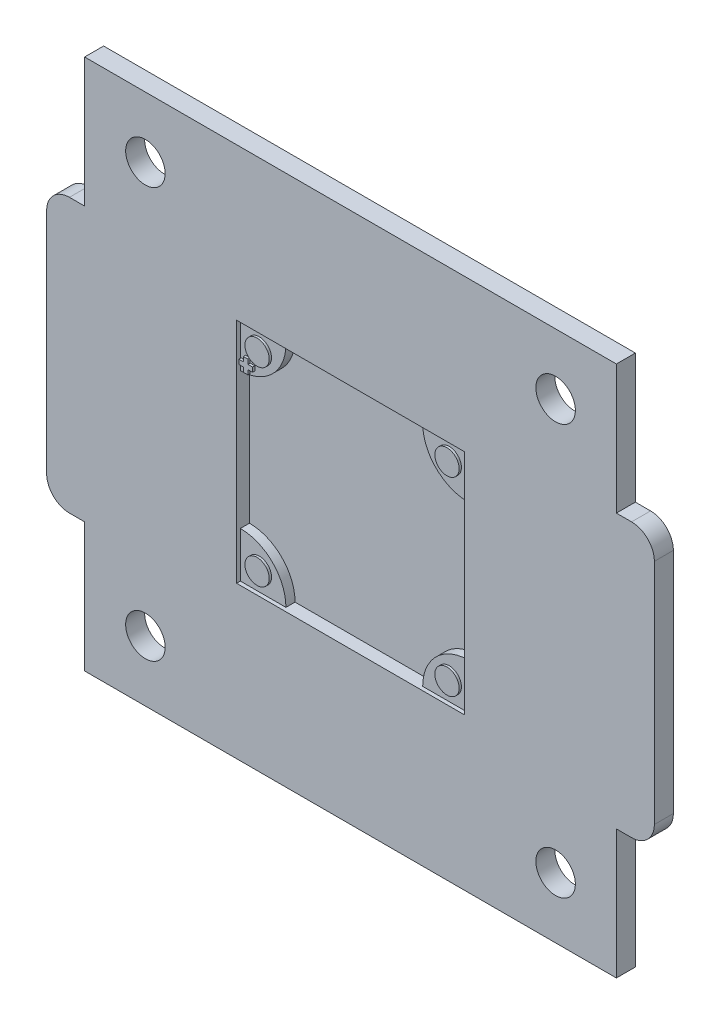
from build123d import *

# Parameters (mm, degrees)
SKETCH_1_W          = 70
SKETCH_1_H          = 70
EXTRUDE_1_DEPTH     = 2.5
SKETCH_2_W          = 30
SKETCH_2_H          = 30
CUT_EXTRUDE_1_DEPTH = 1.7
SKETCH_3_R          = 2.6
CUT_EXTRUDE_2_DEPTH = 3
EXTRUDE_2_DEPTH     = 2
SKETCH_6_R          = 1.6
EXTRUDE_3_DEPTH     = 0.3


with BuildPart() as part:
    # 草图1 → 凸台-拉伸1 (new body)
    with BuildSketch(Plane.XY):
        with BuildLine():
            Line((-2, 17), (0, 17))
            Line((0, 17), (0, 53))
            Line((0, 53), (-2, 53))
            ThreePointArc((-2, 53), (-4.121320344, 52.121320344), (-5, 50))
            Line((-5, 50), (-5, 20))
            ThreePointArc((-5, 20), (-4.121320344, 17.878679656), (-2, 17))
        make_face()
        with Locations((35, 35)):
            Rectangle(SKETCH_1_W, SKETCH_1_H)
        with BuildLine():
            Line((70, 53), (70, 17))
            Line((70, 17), (72, 17))
            ThreePointArc((72, 17), (74.121320344, 17.878679656), (75, 20))
            Line((75, 20), (75, 50))
            ThreePointArc((75, 50), (74.121320344, 52.121320344), (72, 53))
            Line((72, 53), (70, 53))
        make_face()
    extrude(amount=EXTRUDE_1_DEPTH)

    # 草图2 → 切除-拉伸1 (cut)
    with BuildSketch(Plane.XY.offset(2.5)):
        with Locations((35, 35)):
            Rectangle(SKETCH_2_W, SKETCH_2_H)
    extrude(amount=-CUT_EXTRUDE_1_DEPTH, mode=Mode.SUBTRACT)

    # 草图3 → 切除-拉伸2 (cut)
    with BuildSketch(Plane.XY.offset(2.5)):
        with Locations((8, 62)):
            Circle(SKETCH_3_R)
        with Locations((62, 62)):
            Circle(SKETCH_3_R)
        with Locations((8, 8)):
            Circle(SKETCH_3_R)
        with Locations((62, 8)):
            Circle(SKETCH_3_R)
    extrude(amount=-CUT_EXTRUDE_2_DEPTH, mode=Mode.SUBTRACT)

    # 草图4 → 凸台-拉伸2 (add)
    with BuildSketch(Plane.XY):
        with BuildLine():
            Line((20, 44), (20, 50))
            Line((20, 50), (26, 50))
            ThreePointArc((26, 50), (24.242640687, 45.757359313), (20, 44))
        make_face()
        with BuildLine():
            Line((50, 44), (50, 50))
            Line((50, 50), (44, 50))
            ThreePointArc((44, 50), (45.757359313, 45.757359313), (50, 44))
        make_face()
        with BuildLine():
            Line((50, 20), (44, 20))
            ThreePointArc((44, 20), (45.757359313, 24.242640687), (50, 26))
            Line((50, 26), (50, 20))
        make_face()
        with BuildLine():
            Line((20, 26), (20, 20))
            Line((20, 20), (26, 20))
            ThreePointArc((26, 20), (24.242640687, 24.242640687), (20, 26))
        make_face()
    extrude(amount=EXTRUDE_2_DEPTH)

    # 草图6 → 凸台-拉伸3 (add)
    with BuildSketch(Plane.XY.offset(2)):
        with Locations((22.5, 47.5)):
            Circle(SKETCH_6_R)
        with Locations((47.5, 47.5)):
            Circle(SKETCH_6_R)
        with Locations((47.5, 22.5)):
            Circle(SKETCH_6_R)
        with Locations((22.5, 22.5)):
            Circle(SKETCH_6_R)
        Polygon((20.1, 45.5), (20.7, 45.5), (20.7, 46.1), (21.3, 46.1), (21.3, 45.5), (21.9, 45.5), (21.9, 44.9), (21.3, 44.9), (21.3, 44.3), (20.7, 44.3), (20.7, 44.9), (20.1, 44.9), align=None)
    extrude(amount=EXTRUDE_3_DEPTH)


solid = part.part
